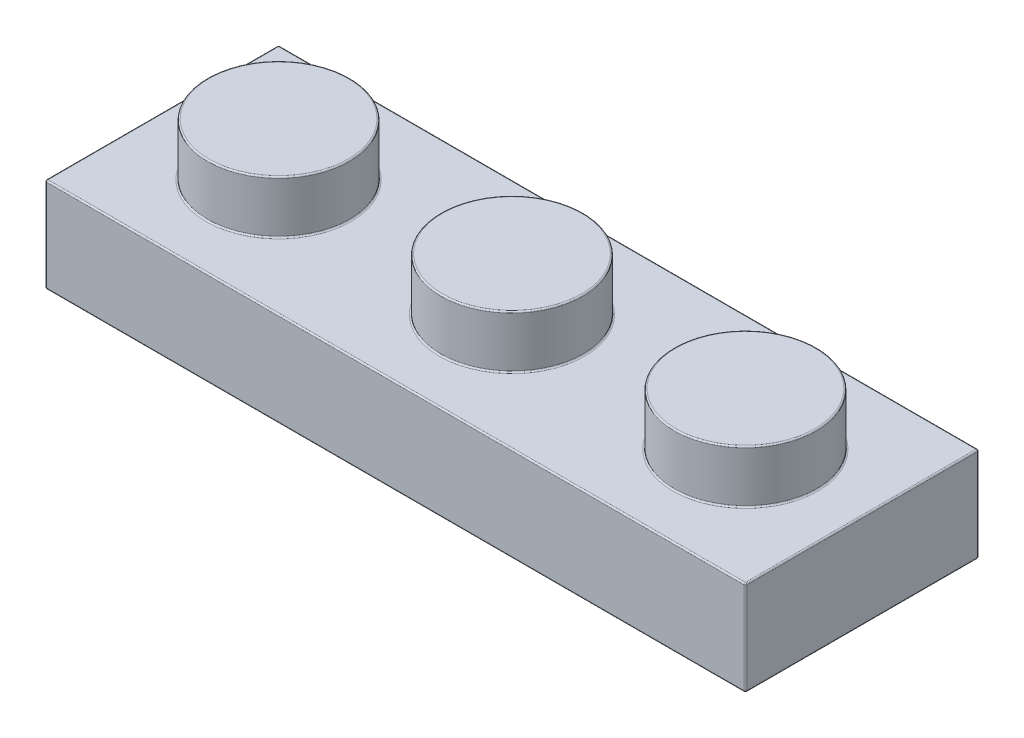
from build123d import *

# Parameters (mm, degrees)
SKETCH1_W       = 7.96
SKETCH1_H       = 7.96
EXTRUDE1_DEPTH  = 3.22
SKETCH2_R       = 2.425
EXTRUDE2_DEPTH  = 1.8
LPATTERN1_COUNT = 3
LPATTERN1_PITCH = 7.96
SHELL1_T        = -1.55
SKETCH3_W       = 20.78
SKETCH3_H       = 4.86
EXTRUDE3_DEPTH  = 0.14
SKETCH4_R       = 1.5
SKETCH4_R_2     = 0.64
EXTRUDE4_DEPTH  = 1.81
FILLET1_R       = 0.05


with BuildPart() as part:
    # Sketch1 → Extrude1 (new body)
    with BuildSketch(Plane(origin=(0, 0, 0), x_dir=(1, 0, 0), z_dir=(0, 1, 0))):
        Rectangle(SKETCH1_W, SKETCH1_H)
    extrude1 = extrude(amount=EXTRUDE1_DEPTH)

    # Sketch2 → Extrude2 (add)
    with BuildSketch(Plane(origin=(0, 3.22, 0), x_dir=(1, 0, 0), z_dir=(0, 1, 0))):
        Circle(SKETCH2_R)
    extrude2 = extrude(amount=EXTRUDE2_DEPTH)

    # LPattern1: Extrude1, Extrude2 ×3
    with Locations(*[(i * LPATTERN1_PITCH, 0, 0) for i in range(1, LPATTERN1_COUNT)]):
        add(extrude1)
        add(extrude2)

    # Shell1
    shell1_openings = [part.faces().sort_by_distance(p)[0] for p in [
        (7.96, 0, 0),
    ]]
    offset(amount=SHELL1_T, openings=shell1_openings, kind=Kind.INTERSECTION)

    # Sketch3 → Extrude3 (cut)
    with BuildSketch(Plane.XZ.offset(-1.67)):
        with Locations((7.96, 0)):
            Rectangle(SKETCH3_W, SKETCH3_H)
    extrude(amount=-EXTRUDE3_DEPTH, mode=Mode.SUBTRACT)

    # Sketch4 → Extrude4 (add)
    with BuildSketch(Plane.XZ.offset(-1.81)):
        with Locations((3.98, 0)):
            Circle(SKETCH4_R)
        with Locations((3.98, 0)):
            Circle(SKETCH4_R_2, mode=Mode.SUBTRACT)
        with Locations((11.94, 0)):
            Circle(SKETCH4_R)
        with Locations((11.94, 0)):
            Circle(SKETCH4_R_2, mode=Mode.SUBTRACT)
    extrude(amount=EXTRUDE4_DEPTH)

    # Fillet1
    fillet1_edges = [part.edges().sort_by_distance(p)[0] for p in [
        (-3.98, 3.22, 0),
        (7.96, 3.22, 3.98),
        (-2.425, 3.22, 0),
        (-2.425, 5.02, 0),
        (19.9, 1.61, -3.98),
        (19.9, 3.22, 0),
        (19.9, 0, 0),
        (19.9, 1.61, 3.98),
        (5.535, 3.22, 0),
        (5.535, 5.02, 0),
        (13.495, 3.22, 0),
        (13.495, 5.02, 0),
        (7.96, 0, -2.43),
        (18.35, 0.905, -2.43),
        (-2.43, 0, 0),
        (-2.43, 0.905, -2.43),
        (7.96, 0, 2.43),
        (-2.43, 0.905, 2.43),
        (-0.875, 3.47, 0),
        (18.35, 0, 0),
        (18.35, 0.905, 2.43),
        (7.085, 3.47, 0),
        (15.045, 3.47, 0),
        (7.96, 0, 3.98),
        (-3.98, 0, 0),
        (7.96, 0, -3.98),
        (-0.875, 1.81, 0),
        (7.085, 1.81, 0),
        (15.045, 1.81, 0),
        (7.96, 1.81, 2.43),
        (18.35, 1.81, 0),
        (7.96, 1.81, -2.43),
        (-2.43, 1.81, 0),
        (7.96, 3.22, -3.98),
        (2.48, 1.81, 0),
        (3.34, 1.81, 0),
        (2.48, 0, 0),
        (3.34, 0, 0),
        (-3.98, 1.61, 3.98),
        (-3.98, 1.61, -3.98),
        (10.44, 1.81, 0),
        (11.3, 1.81, 0),
        (10.44, 0, 0),
        (11.3, 0, 0),
    ]]
    fillet(fillet1_edges, radius=FILLET1_R)


solid = part.part
